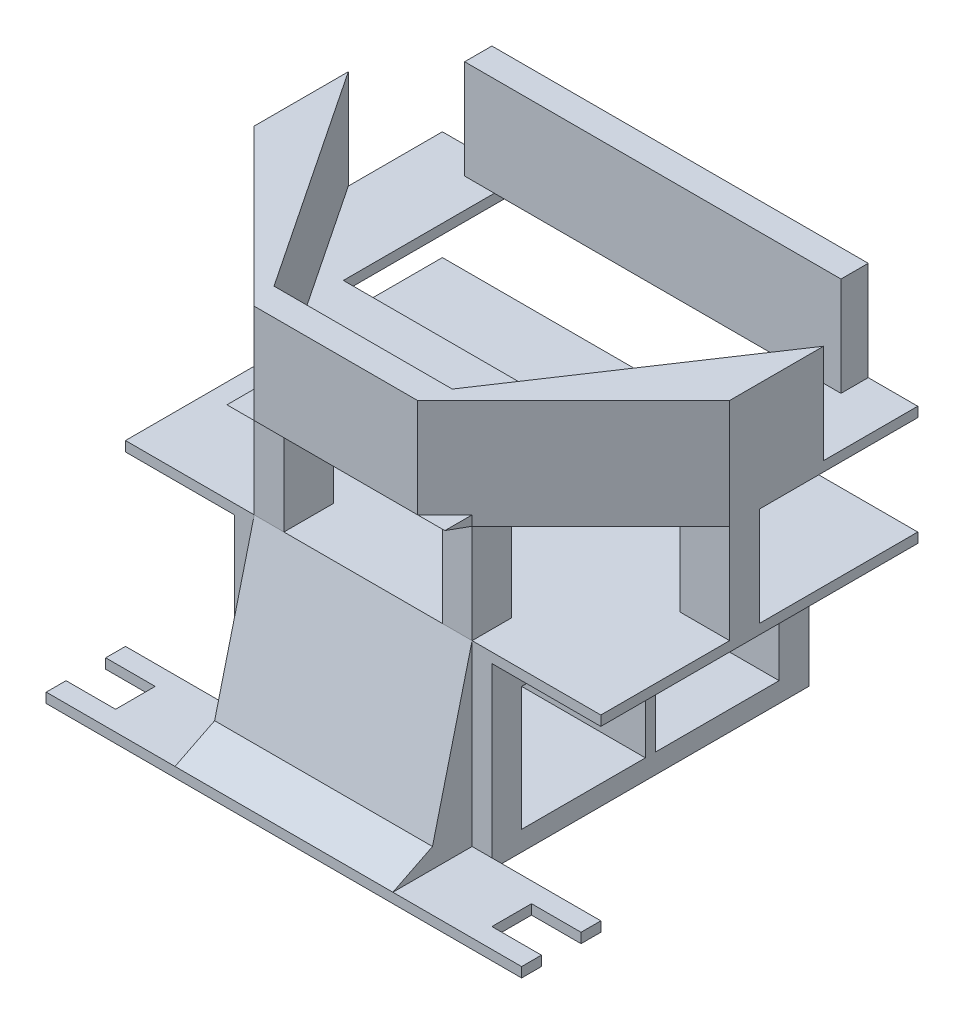
from build123d import *

# Parameters (mm, degrees)
SKETCH1_W            = 27
SKETCH1_H            = 18
BOSS_EXTRUDE1_DEPTH  = 26
SKETCH2_W            = 12.5
SKETCH2_H            = 12.5
CUT_EXTRUDE1_DEPTH   = 26
SKETCH4_W            = 26
SKETCH4_H            = 18
BOSS_EXTRUDE2_DEPTH  = 5
SKETCH5_W            = 12.5
SKETCH5_H            = 12.5
CUT_EXTRUDE2_DEPTH   = 26
SKETCH7_W            = 26
SKETCH7_H            = 1
BOSS_EXTRUDE3_DEPTH  = 8
SKETCH8_W            = 48
SKETCH8_H            = 8
BOSS_EXTRUDE4_DEPTH  = 1
SKETCH9_W            = 5
SKETCH9_H            = 4
CUT_EXTRUDE4_DEPTH   = 8
SKETCH10_W           = 48
SKETCH10_H           = 32
BOSS_EXTRUDE5_DEPTH  = 1
SKETCH12_W           = 5
SKETCH12_H           = 3
BOSS_EXTRUDE7_DEPTH  = 10
SKETCH14_W           = 3
SKETCH14_H           = 5
SKETCH14_H_2         = 4
BOSS_EXTRUDE8_DEPTH  = 10
BOSS_EXTRUDE9_DEPTH  = 1
SKETCH17_W           = 38
SKETCH17_H           = 2.75142147
BOSS_EXTRUDE11_DEPTH = 10
BOSS_EXTRUDE12_DEPTH = 10
BOSS_EXTRUDE13_DEPTH = 22
SKETCH21_W           = 32
SKETCH21_H           = 18
CUT_EXTRUDE5_DEPTH   = 1
SKETCH22_W           = 22
SKETCH22_H           = 18
BOSS_EXTRUDE14_DEPTH = 8
CUT_EXTRUDE6_DEPTH   = 40
BOSS_EXTRUDE17_DEPTH = 10


with BuildPart() as part:
    # Sketch1 → Boss-Extrude1 (new body)
    with BuildSketch(Plane(origin=(0, 0, 0), x_dir=(0, 0, -1), z_dir=(1, 0, 0))):
        with Locations((13.5, 9)):
            Rectangle(SKETCH1_W, SKETCH1_H)
    extrude(amount=BOSS_EXTRUDE1_DEPTH)

    # Sketch2 → Cut-Extrude1 (cut)
    with BuildSketch(Plane(origin=(26, 0, 0), x_dir=(0, 0, -1), z_dir=(1, 0, 0))):
        with Locations((9.25, 8.25)):
            Rectangle(SKETCH2_W, SKETCH2_H)
    extrude(amount=-CUT_EXTRUDE1_DEPTH, mode=Mode.SUBTRACT)

    # Sketch4 → Boss-Extrude2 (add)
    with BuildSketch(Plane(origin=(0, 0, -27), x_dir=(-1, 0, 0), z_dir=(0, 0, -1))):
        with Locations((-13, 9)):
            Rectangle(SKETCH4_W, SKETCH4_H)
    extrude(amount=BOSS_EXTRUDE2_DEPTH)

    # Sketch5 → Cut-Extrude2 (cut)
    with BuildSketch(Plane(origin=(26, 0, 0), x_dir=(0, 0, -1), z_dir=(1, 0, 0))):
        with Locations((22.75, 8.25)):
            Rectangle(SKETCH5_W, SKETCH5_H)
    extrude(amount=-CUT_EXTRUDE2_DEPTH, mode=Mode.SUBTRACT)

    # Sketch7 → Boss-Extrude3 (add)
    with BuildSketch(Plane.XY):
        with Locations((13, 0.5)):
            Rectangle(SKETCH7_W, SKETCH7_H)
    extrude(amount=BOSS_EXTRUDE3_DEPTH)

    # Sketch8 → Boss-Extrude4 (add)
    with BuildSketch(Plane(origin=(0, 1, 0), x_dir=(1, 0, 0), z_dir=(0, 1, 0))):
        with Locations((13, -4)):
            Rectangle(SKETCH8_W, SKETCH8_H)
    extrude(amount=-BOSS_EXTRUDE4_DEPTH)

    # Sketch9 → Cut-Extrude4 (cut)
    with BuildSketch(Plane(origin=(0, 1, 0), x_dir=(1, 0, 0), z_dir=(0, 1, 0))):
        with Locations((-8.5, -4)):
            Rectangle(SKETCH9_W, SKETCH9_H)
        with Locations((34.5, -4)):
            Rectangle(SKETCH9_W, SKETCH9_H)
    extrude(amount=-CUT_EXTRUDE4_DEPTH, mode=Mode.SUBTRACT)

    # Sketch10 → Boss-Extrude5 (add)
    with BuildSketch(Plane(origin=(0, 18, 0), x_dir=(1, 0, 0), z_dir=(0, 1, 0))):
        with Locations((13, 16)):
            Rectangle(SKETCH10_W, SKETCH10_H)
    extrude(amount=BOSS_EXTRUDE5_DEPTH)

    # Sketch12 → Boss-Extrude7 (add)
    with BuildSketch(Plane(origin=(0, 19, 0), x_dir=(1, 0, 0), z_dir=(0, 1, 0))):
        with Locations((-8.5, 14.5)):
            Rectangle(SKETCH12_W, SKETCH12_H)
        with Locations((34.5, 14.5)):
            Rectangle(SKETCH12_W, SKETCH12_H)
    extrude(amount=BOSS_EXTRUDE7_DEPTH)

    # Sketch14 → Boss-Extrude8 (add)
    with BuildSketch(Plane(origin=(0, 19, 0), x_dir=(1, 0, 0), z_dir=(0, 1, 0))):
        with Locations((3.5, 2.5)):
            Rectangle(SKETCH14_W, SKETCH14_H)
        with Locations((22.5, 2)):
            Rectangle(SKETCH14_W, SKETCH14_H_2)
    extrude(amount=BOSS_EXTRUDE8_DEPTH)

    # Sketch15 → Boss-Extrude9 (add)
    with BuildSketch(Plane(origin=(0, 29, 0), x_dir=(1, 0, 0), z_dir=(0, 1, 0))):
        Polygon((2, 0), (-11, 13), (-11, 16), (-11, 32), (37, 32), (37, 13), (24, 0), align=None)
    extrude(amount=BOSS_EXTRUDE9_DEPTH)

    # Sketch17 → Boss-Extrude11 (add)
    with BuildSketch(Plane(origin=(0, 30, 0), x_dir=(1, 0, 0), z_dir=(0, 1, 0))):
        with Locations((13, 30.624289265)):
            Rectangle(SKETCH17_W, SKETCH17_H)
    extrude(amount=BOSS_EXTRUDE11_DEPTH)



with BuildPart() as body_2:
    # Sketch18 → Boss-Extrude12 (new body)
    with BuildSketch(Plane(origin=(0, 30, 0), x_dir=(1, 0, 0), z_dir=(0, 1, 0))):
        Polygon((2, 0), (4.75142147, -2.75142147), (21.24857853, -2.75142147), (24, 0), align=None)
    extrude(amount=BOSS_EXTRUDE12_DEPTH)


with BuildPart() as part_1:
    add(part.part)

    add(body_2.part)  # Boss-Extrude13 merges body 2
    # Sketch19 → Boss-Extrude13 (add)
    with BuildSketch(Plane(origin=(2, 30, 0), x_dir=(0, 0, 1), z_dir=(-1, 0, 0))):
        Polygon((0, -1), (2.75142147, 0), (0, 0), align=None)
    extrude(amount=-BOSS_EXTRUDE13_DEPTH)

    # Sketch21 → Cut-Extrude5 (cut)
    with BuildSketch(Plane(origin=(0, 30, 0), x_dir=(1, 0, 0), z_dir=(0, 1, 0))):
        with Locations((13, 23)):
            Rectangle(SKETCH21_W, SKETCH21_H)
    extrude(amount=-CUT_EXTRUDE5_DEPTH, mode=Mode.SUBTRACT)

    # Sketch22 → Boss-Extrude14 (add)
    with BuildSketch(Plane.XY):
        with Locations((13, 10)):
            Rectangle(SKETCH22_W, SKETCH22_H)
    extrude(amount=BOSS_EXTRUDE14_DEPTH)

    # Sketch23 → Cut-Extrude6 (cut)
    with BuildSketch(Plane(origin=(24, 0, 0), x_dir=(0, 0, -1), z_dir=(1, 0, 0))):
        Polygon((0, 19), (-4, 3), (-8, 1), (-8, 19), align=None)
    extrude(amount=-CUT_EXTRUDE6_DEPTH, mode=Mode.SUBTRACT)

    # Sketch25 → Boss-Extrude17 (add)
    with BuildSketch(Plane(origin=(0, 30, 0), x_dir=(1, 0, 0), z_dir=(0, 1, 0))):
        Polygon((24, 0), (37, 13), (37, 22.5), (22, 0), align=None)
        Polygon((2, 0), (-11, 13), (-11, 22.5), (4, 0), align=None)
    extrude(amount=BOSS_EXTRUDE17_DEPTH)


solid = part_1.part
